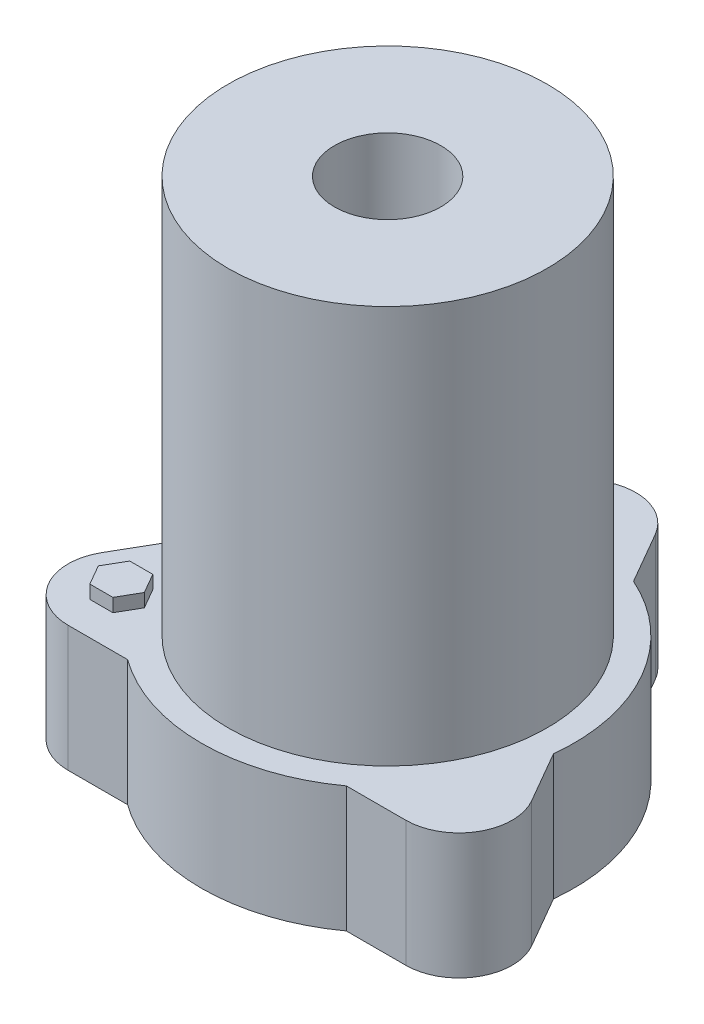
from build123d import *

# Parameters (mm, degrees)
BOSS_EXTRUDE1_DEPTH = 60
BOSS_EXTRUDE2_DEPTH = 6.35
SKETCH3_R           = 76.2
BOSS_EXTRUDE3_DEPTH = 250
SKETCH4_R           = 25.4
CUT_EXTRUDE1_DEPTH  = 50.8


with BuildPart() as part:
    # Sketch1 → Boss-Extrude1 (new body)
    with BuildSketch(Plane(origin=(0, 0, 0), x_dir=(1, 0, 0), z_dir=(0, 1, 0))):
        with BuildLine():
            ThreePointArc((-36.198972693, 81.196332281), (-76.989658396, 44.45), (-88.417572796, -9.248936198))
            Line((-88.417572796, -9.248936198), (-102.619500233, -33.847396084))
            ThreePointArc((-102.619500233, -33.847396084), (-102.619500233, -59.247396084), (-80.622454977, -71.947396084))
            Line((-80.622454977, -71.947396084), (-52.218600103, -71.947396084))
            ThreePointArc((-52.218600103, -71.947396084), (0, -88.9), (52.218600103, -71.947396084))
            Line((52.218600103, -71.947396084), (80.622454977, -71.947396084))
            ThreePointArc((80.622454977, -71.947396084), (102.619500233, -59.247396084), (102.619500233, -33.847396084))
            Line((102.619500233, -33.847396084), (88.417572796, -9.248936198))
            ThreePointArc((88.417572796, -9.248936198), (76.989658396, 44.45), (36.198972693, 81.196332281))
            Line((36.198972693, 81.196332281), (21.997045256, 105.794792168))
            ThreePointArc((21.997045256, 105.794792168), (0, 118.494792168), (-21.997045256, 105.794792168))
            Line((-21.997045256, 105.794792168), (-36.198972693, 81.196332281))
        make_face()
        with BuildLine():
            ThreePointArc((-75.786490968, -7.927659598), (-65.991135768, 38.1), (-31.02769088, 69.596856241))
            ThreePointArc((-31.02769088, 69.596856241), (0, 76.2), (31.02769088, 69.596856241))
            ThreePointArc((31.02769088, 69.596856241), (63.916938463, 41.485720163), (76.2, 0))
            ThreePointArc((76.2, 0), (76.096552523, -3.969218324), (75.786490968, -7.927659598))
            ThreePointArc((75.786490968, -7.927659598), (65.991135768, -38.1), (44.758800089, -61.669196643))
            ThreePointArc((44.758800089, -61.669196643), (0, -76.2), (-44.758800089, -61.669196643))
            ThreePointArc((-44.758800089, -61.669196643), (-65.991135768, -38.1), (-75.786490968, -7.927659598))
        make_face(mode=Mode.SUBTRACT)
    extrude(amount=BOSS_EXTRUDE1_DEPTH)

    # Sketch2 → Boss-Extrude2 (add)
    with BuildSketch(Plane(origin=(0, 60, 0), x_dir=(1, 0, 0), z_dir=(0, 1, 0))):
        Polygon((-69.623932349, -46.547396084), (-75.123193663, -37.022396084), (-86.121716291, -37.022396084), (-91.620977605, -46.547396084), (-86.121716291, -56.072396084), (-75.123193663, -56.072396084), align=None)
    extrude(amount=BOSS_EXTRUDE2_DEPTH)

    # Sketch3 → Boss-Extrude3 (add)
    with BuildSketch(Plane.XZ):
        with Locations(Location((0, 0, 0), (0, 0, 270))):
            Circle(SKETCH3_R)
    extrude(amount=-BOSS_EXTRUDE3_DEPTH)

    # Sketch4 → Cut-Extrude1 (cut)
    with BuildSketch(Plane(origin=(0, 250, 0), x_dir=(1, 0, 0), z_dir=(0, 1, 0))):
        with Locations(Location((0, 0, 0), (0, 0, 270))):
            Circle(SKETCH4_R)
    extrude(amount=-CUT_EXTRUDE1_DEPTH, mode=Mode.SUBTRACT)


solid = part.part
